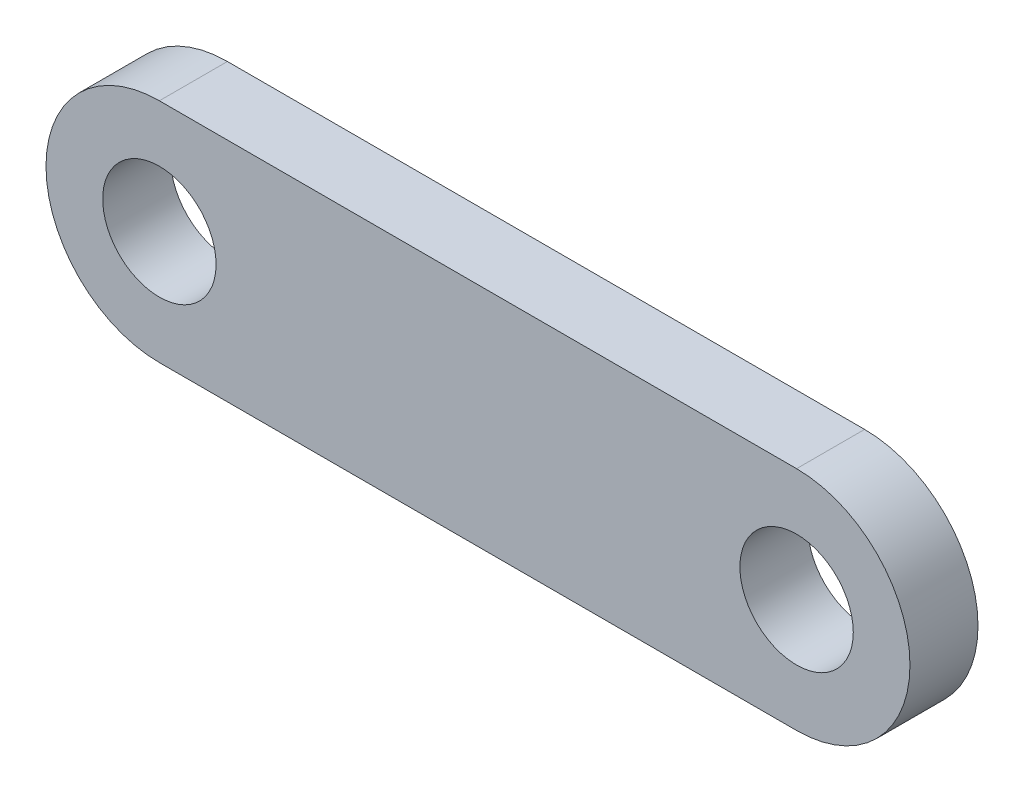
from build123d import *

# Parameters (mm, degrees)
CROQUIS1_R              = 5
SALIENTE_EXTRUIR1_DEPTH = 6


with BuildPart() as part:
    # Croquis1 → Saliente-Extruir1 (new body)
    with BuildSketch(Plane.XY):
        with BuildLine():
            Line((-28.782828998, 10), (27.417171002, 10))
            ThreePointArc((27.417171002, 10), (37.417171002, 0), (27.417171002, -10))
            Line((27.417171002, -10), (-28.782828998, -10))
            ThreePointArc((-28.782828998, -10), (-38.782828998, 0), (-28.782828998, 10))
        make_face()
        with Locations((-28.782828998, 0)):
            Circle(CROQUIS1_R, mode=Mode.SUBTRACT)
        with Locations((27.417171002, 0)):
            Circle(CROQUIS1_R, mode=Mode.SUBTRACT)
    extrude(amount=SALIENTE_EXTRUIR1_DEPTH)


solid = part.part
